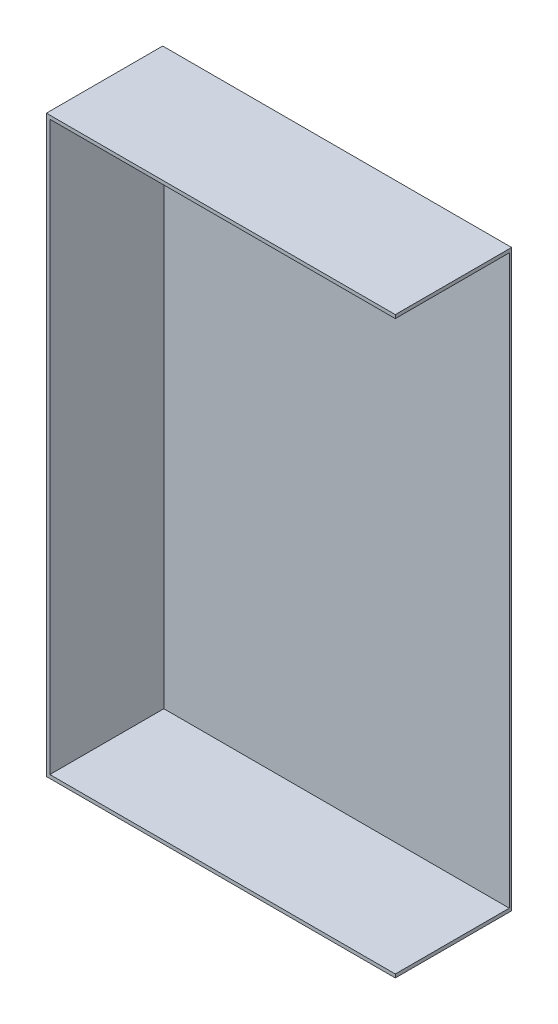
from build123d import *

# Parameters (mm, degrees)
SKETCH1_W           = 381
SKETCH1_H           = 627.38
BOSS_EXTRUDE1_DEPTH = 127
SKETCH2_W           = 377.19
SKETCH2_H           = 619.76
CUT_EXTRUDE1_DEPTH  = 124.46


with BuildPart() as part:
    # Sketch1 → Boss-Extrude1 (new body)
    with BuildSketch(Plane.XY):
        with Locations((190.5, 313.69)):
            Rectangle(SKETCH1_W, SKETCH1_H)
    extrude(amount=BOSS_EXTRUDE1_DEPTH)

    # Sketch2 → Cut-Extrude1 (cut)
    with BuildSketch(Plane.XY.offset(127)):
        with Locations((192.405, 313.69)):
            Rectangle(SKETCH2_W, SKETCH2_H)
    extrude(amount=-CUT_EXTRUDE1_DEPTH, mode=Mode.SUBTRACT)


solid = part.part
